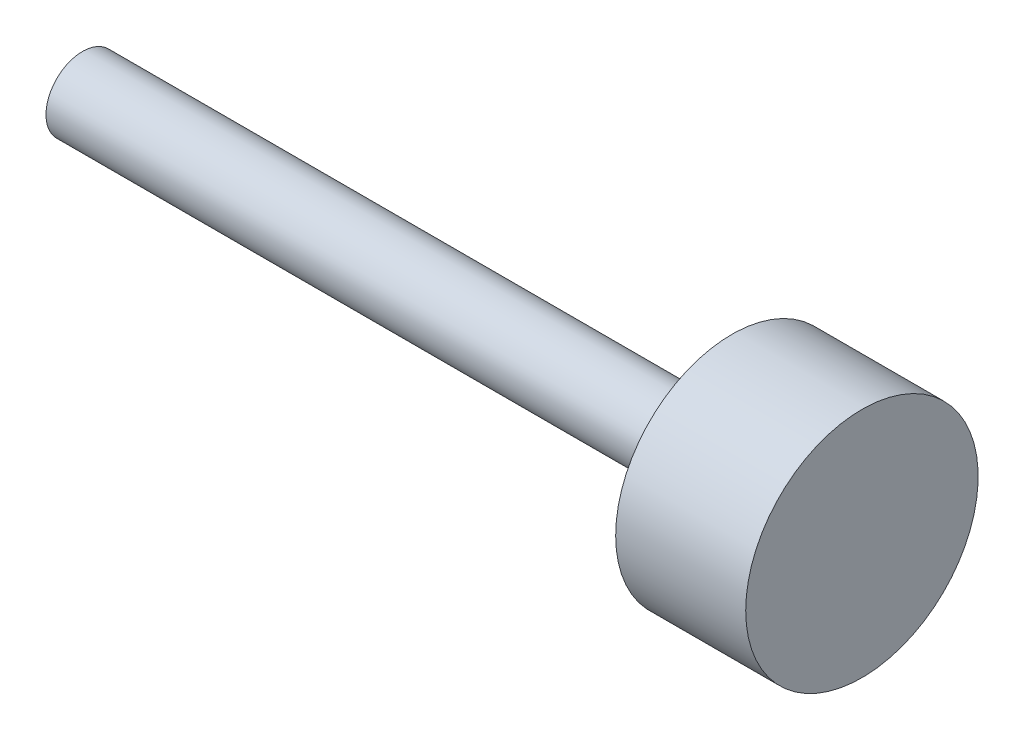
from build123d import *

# Parameters (mm, degrees)
HOLE1_D           = 9.73836
HOLE1_DEPTH       = 28.062477616
HOLE1_CSINK_D     = 11.1125
HOLE1_CSINK_ANGLE = 90
HOLE1_TIP         = 2.811222384


with BuildPart() as part:
    # Sketch1 → Revolve1 (revolve)
    with BuildSketch(Plane.XY):
        Polygon((-22.225, 0), (-22.225, 8.001), (119.9642, 8.001), (119.9642, 25.4508), (148.4376, 25.4508), (148.4376, 0), align=None)
    revolve(axis=Axis((148.4376, 0, 0), (-1, 0, 0)))

    # Hole1
    with Locations(Plane.ZY.offset(22.225)):
        with Locations((0, 0)):
            CounterSinkHole(HOLE1_D / 2, HOLE1_CSINK_D / 2, depth=HOLE1_DEPTH, counter_sink_angle=HOLE1_CSINK_ANGLE)
            with Locations((0, 0, -(HOLE1_DEPTH + HOLE1_TIP / 2))):  # 120° drill point
                Cone(0, HOLE1_D / 2, HOLE1_TIP, mode=Mode.SUBTRACT)


solid = part.part
